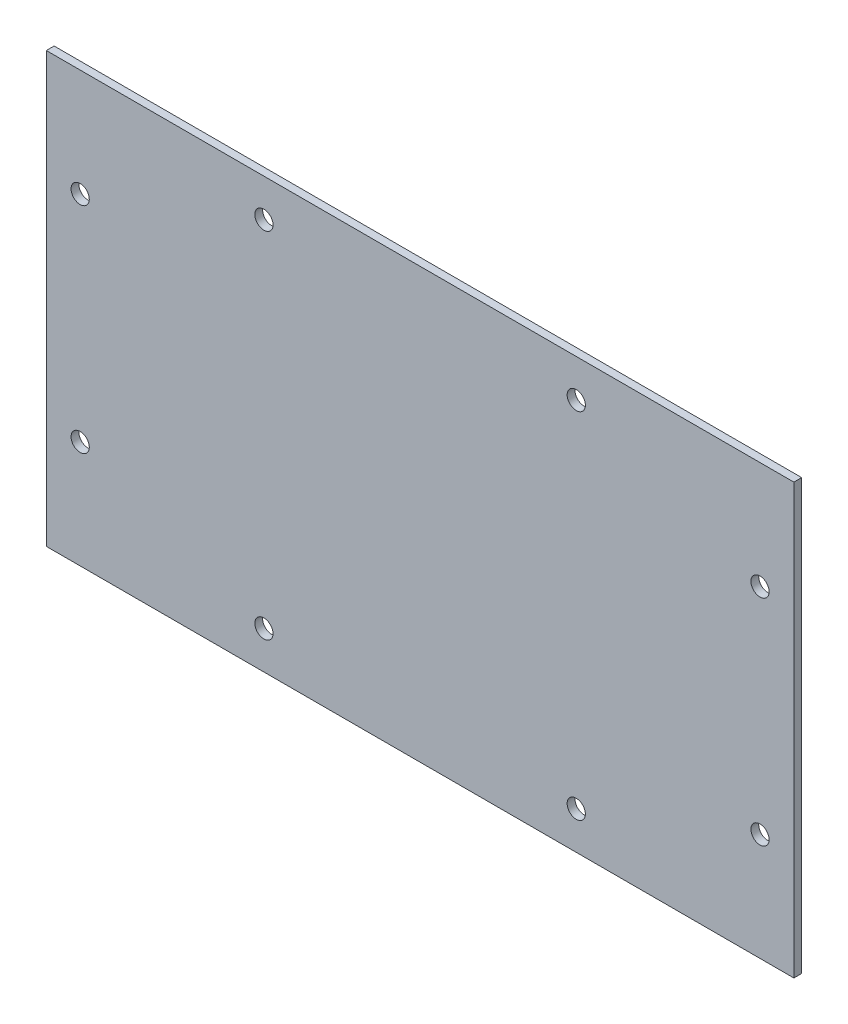
from build123d import *

# Parameters (mm, degrees)
SKETCH2_W           = 287.200000002
SKETCH2_H           = 165
SKETCH2_R           = 3.5
BOSS_EXTRUDE2_DEPTH = 3
SKETCH3_R           = 3.5
CUT_EXTRUDE1_DEPTH  = 3


with BuildPart() as part:
    # Sketch2 → Boss-Extrude2 (new body)
    with BuildSketch(Plane.XY):
        Rectangle(SKETCH2_W, SKETCH2_H)
        with Locations((-130.600000001, 41.25)):
            Circle(SKETCH2_R, mode=Mode.SUBTRACT)
        with Locations((-130.600000001, -41.25)):
            Circle(SKETCH2_R, mode=Mode.SUBTRACT)
        with Locations((130.600000001, -41.25)):
            Circle(SKETCH2_R, mode=Mode.SUBTRACT)
        with Locations((130.600000001, 41.25)):
            Circle(SKETCH2_R, mode=Mode.SUBTRACT)
    extrude(amount=BOSS_EXTRUDE2_DEPTH)

    # Sketch3 → Cut-Extrude1 (cut)
    with BuildSketch(Plane.XY.offset(3)):
        with Locations((-60, 68)):
            Circle(SKETCH3_R)
        with Locations((60, 68)):
            Circle(SKETCH3_R)
        with Locations((60, -68)):
            Circle(SKETCH3_R)
        with Locations((-60, -68)):
            Circle(SKETCH3_R)
    extrude(amount=-CUT_EXTRUDE1_DEPTH, mode=Mode.SUBTRACT)


solid = part.part
